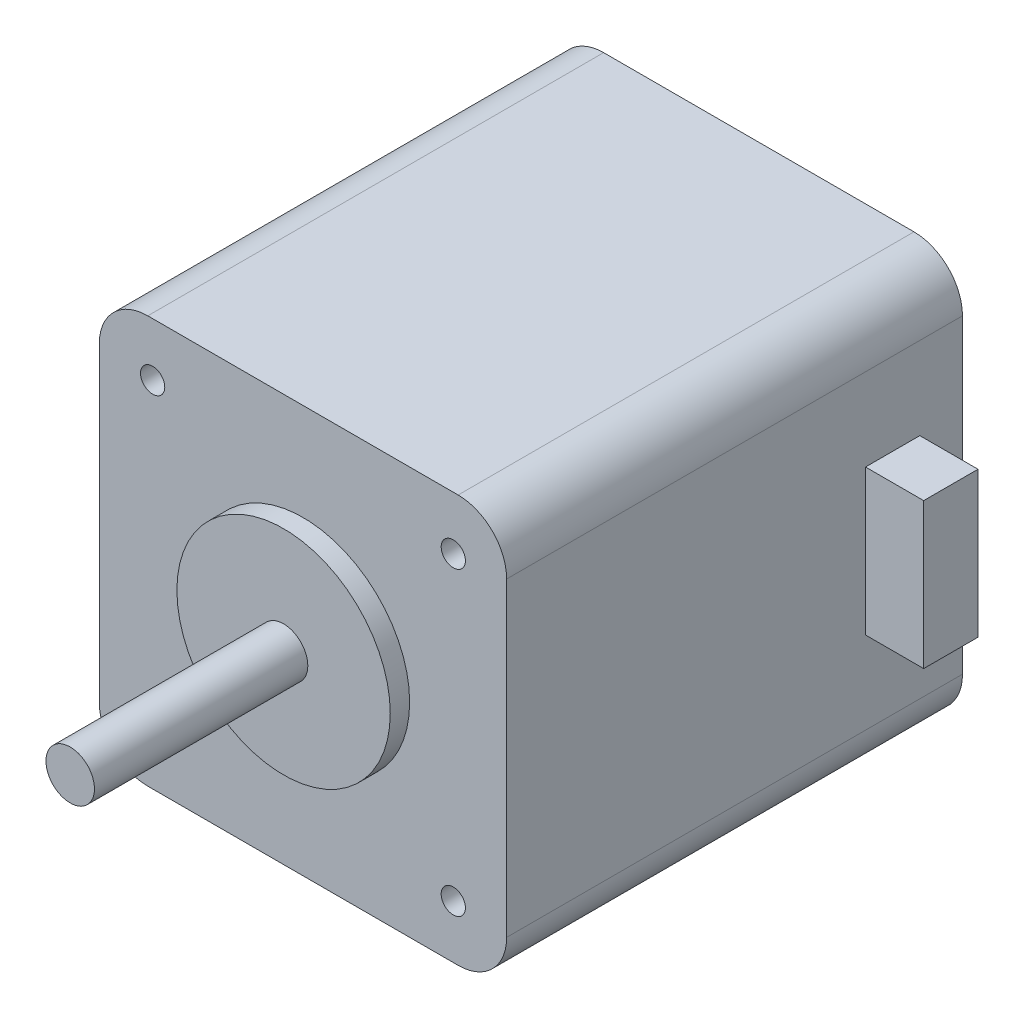
from build123d import *

# Parameters (mm, degrees)
SKETCH1_W           = 42
SKETCH1_H           = 42
BOSS_EXTRUDE1_DEPTH = 47
SKETCH2_R           = 2.5
BOSS_EXTRUDE4_DEPTH = 24
SKETCH2_5_R         = 11
SKETCH2_5_R_2       = 2.5
BOSS_EXTRUDE5_DEPTH = 2
CIRPATTERN1_COUNT   = 4
FILLET1_R           = 5
SKETCH14_W          = 5.6
SKETCH14_H          = 15
BOSS_EXTRUDE6_DEPTH = 6


with BuildPart() as part:
    # Sketch1 → Boss-Extrude1 (new body)
    with BuildSketch(Plane.XY):
        Rectangle(SKETCH1_W, SKETCH1_H)
    extrude(amount=BOSS_EXTRUDE1_DEPTH)

    # Sketch2 → Boss-Extrude4 (add)
    with BuildSketch(Plane.XY.offset(47)):
        Circle(SKETCH2_R)
    extrude(amount=BOSS_EXTRUDE4_DEPTH)

    # Sketch2_5 → Boss-Extrude5 (add)
    with BuildSketch(Plane.XY.offset(47)):
        Circle(SKETCH2_5_R)
        Circle(SKETCH2_5_R_2, mode=Mode.SUBTRACT)
    extrude(amount=BOSS_EXTRUDE5_DEPTH)

    # Sketch12 → M3 Tapped Hole3 (revolve, cut)
    with BuildSketch(Plane(origin=(-15.5, 15.5, 47), x_dir=(0, -1, 0), z_dir=(1, 0, 0))):
        Polygon((0, 0), (0, 6.751075774), (1.25, 6), (1.25, 0), align=None)
    m3_tapped_hole3 = revolve(axis=Axis((-15.5, 15.5, 53.35), (0, 0, -1)), mode=Mode.SUBTRACT)

    # CirPattern1: M3 Tapped Hole3 ×4 about axis
    cirpattern1_axis = Axis((0, 0, 49), (0, 0, 1))
    for i in range(1, CIRPATTERN1_COUNT):
        add(m3_tapped_hole3.rotate(cirpattern1_axis, i * 360 / CIRPATTERN1_COUNT), mode=Mode.SUBTRACT)

    # Fillet1
    fillet1_edges = [part.edges().sort_by_distance(p)[0] for p in [
        (-21, -21, 23.5),
        (-21, 21, 23.5),
        (21, -21, 23.5),
        (21, 21, 23.5),
    ]]
    fillet(fillet1_edges, radius=FILLET1_R)

    # Sketch14 → Boss-Extrude6 (add)
    with BuildSketch(Plane(origin=(21, 0, 0), x_dir=(0, 0, -1), z_dir=(1, 0, 0))):
        with Locations((-7.2, 0)):
            Rectangle(SKETCH14_W, SKETCH14_H)
    extrude(amount=BOSS_EXTRUDE6_DEPTH)


solid = part.part
